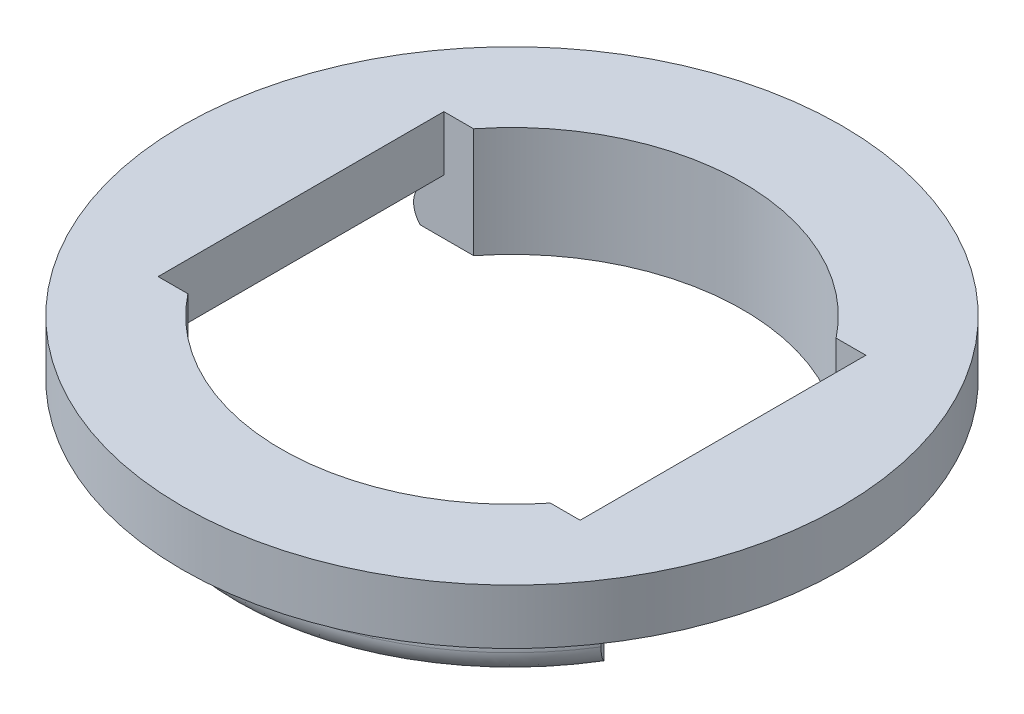
from build123d import *

# Parameters (mm, degrees)
SKETCH1_R               = 15.000000000000009
BOSS_EXTRUDE1_DEPTH     = 2.5
BOSS_EXTRUDE2_DEPTH     = 2.5
CUT_EXTRUDE1_DEPTH      = 22.360009363293848
CUT_EXTRUDE1_DEPTH_BACK = 22.360009363293848


with BuildPart() as part:
    # Sketch1 → Boss-Extrude1 (new body)
    with BuildSketch(Plane(origin=(0, 0, 0), x_dir=(1, 0, 0), z_dir=(0, 1, 0))):
        Circle(SKETCH1_R)
        Polygon((-9.600000000000001, 6.500000000000001), (9.599999999999998, 6.500000000000001), (9.600000000000001, -6.499999999999999), (-9.6, -6.499999999999999), align=None, mode=Mode.SUBTRACT)
    extrude(amount=BOSS_EXTRUDE1_DEPTH)

    # Sketch2 → Boss-Extrude2 (add)
    with BuildSketch(Plane.XZ):
        with BuildLine():
            ThreePointArc((10.677078252031343, 6.499999999999946), (1.9505e-13, 12.5), (-10.677078252031139, 6.5000000000002816))
            Line((-10.677078252031041, 6.500000000000222), (-8.246211251235344, 6.499999999999985))
            ThreePointArc((-8.246211251235334, 6.499999999999984), (9.623e-14, 10.5), (8.246211251235454, 6.499999999999831))
            Line((8.246211251235511, 6.499999999999877), (10.677078252031361, 6.499999999999957))
        make_face()
        with BuildLine():
            Line((-8.24621125123534, -6.499999999999991), (-10.67707825203104, -6.500000000000227))
            ThreePointArc((-10.677078252031139, -6.500000000000285), (1.9754e-13, -12.5), (10.677078252031343, -6.499999999999948))
            Line((10.677078252031361, -6.499999999999961), (8.246211251235515, -6.499999999999878))
            ThreePointArc((8.24621125123545, -6.499999999999835), (9.133e-14, -10.5), (-8.246211251235332, -6.499999999999985))
        make_face()
    extrude(amount=BOSS_EXTRUDE2_DEPTH)

    # Sketch2_3 → Cut-Extrude1 (cut, two sides: drawn at the far end of the back side and taken through both)
    with BuildSketch(Plane.XZ.offset(-CUT_EXTRUDE1_DEPTH_BACK)):
        with BuildLine():
            ThreePointArc((8.246211251235135, 6.500000000000237), (-8.68e-15, 10.5), (-8.246211251235145, 6.500000000000222))
            Line((-8.246211251235067, 6.499999999999999), (8.24621125123505, 6.499999999999999))
        make_face()
        with BuildLine():
            Line((8.246211251235048, -6.500000000000003), (-8.246211251235064, -6.500000000000003))
            ThreePointArc((-8.246211251235142, -6.5000000000002265), (-1.125e-14, -10.5), (8.24621125123513, -6.500000000000245))
        make_face()
    extrude(amount=CUT_EXTRUDE1_DEPTH + CUT_EXTRUDE1_DEPTH_BACK, mode=Mode.SUBTRACT)

    # Sweep2: sweep along a curve in space
    with BuildLine() as sweep2_path:
        ThreePointArc((10.677078252031313, -2.5, 6.499999999999999), (-1.78e-15, -2.5, 12.5), (-10.677078252031313, -2.5, 6.499999999999999))
    # Sketch4 → Sweep2 (sweep)
    with BuildSketch(Plane(origin=(2.88e-15, 0, 6.499999999999995), x_dir=(-1, 0, 4.4e-16), z_dir=(-4.4e-16, 0, -1))):
        with BuildLine():
            Line((10.677078252031317, -2.5), (10.677078252031317, -1))
            ThreePointArc((10.677078252031317, -1), (10.899296653369037, -1.3461126394649119), (10.977078252031317, -1.75))
            ThreePointArc((10.977078252031317, -1.75), (10.899296653369037, -2.153887360535088), (10.677078252031317, -2.5))
        make_face()
    sweep(path=sweep2_path.line)

    # Sweep4: sweep along a curve in space
    with BuildLine() as sweep4_path:
        ThreePointArc((-10.677078252031311, -2.5, -6.500000000000003), (0, -2.5, -12.500000000000002), (10.677078252031311, -2.5, -6.500000000000003))
    # Sketch11 → Sweep4 (sweep)
    with BuildSketch(Plane.XY.offset(-6.500000000000005)):
        with BuildLine():
            Line((-10.677078252031315, -2.5), (-10.677078252031315, -1))
            ThreePointArc((-10.677078252031315, -1), (-10.899296653369035, -1.3461126394649117), (-10.977078252031315, -1.7499999999999998))
            ThreePointArc((-10.977078252031315, -1.7499999999999998), (-10.899296653369035, -2.1538873605350877), (-10.677078252031315, -2.5))
        make_face()
    sweep(path=sweep4_path.line)


solid = part.part
